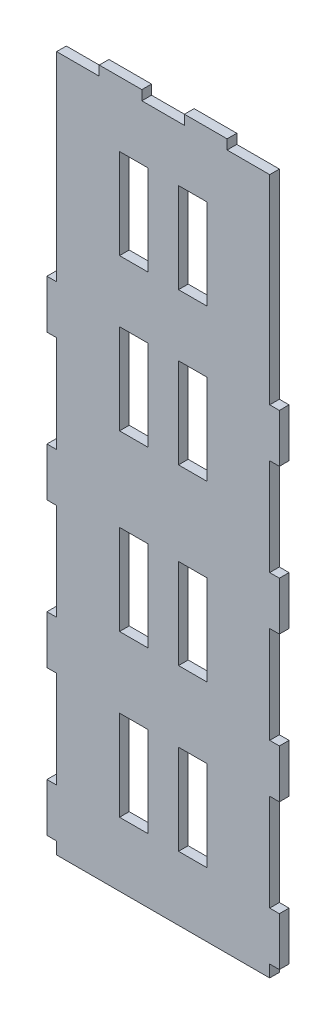
from build123d import *

# Parameters (mm, degrees)
SKETCH1_W           = 11.675882566
SKETCH1_H           = 37.242609939
SKETCH1_H_2         = 37.242609938
BOSS_EXTRUDE1_DEPTH = 4


with BuildPart() as part:
    # Sketch1 → Boss-Extrude1 (new body)
    with BuildSketch(Plane.XY):
        Polygon((6.4, 64.343953413), (-11.2, 64.343953413), (-11.2, 60.343953413), (-28.8, 60.343953413), (-28.8, 64.343953413), (-46.4, 64.343953413), (-46.4, 60.343953413), (-64, 60.343953413), (-64, -21.996281697), (-68, -21.996281697), (-68, -41.996281697), (-64, -41.996281697), (-64, -81.996281697), (-68, -81.996281697), (-68, -101.996281697), (-64, -101.996281697), (-64, -141.996281697), (-68, -141.996281697), (-68, -161.996281697), (-64, -161.996281697), (-64, -201.996281697), (-68, -201.996281697), (-68, -221.996281697), (-64, -221.996281697), (-64, -226.996281697), (24, -226.996281697), (24, -221.996281697), (28, -221.996281697), (28, -201.996281697), (24, -201.996281697), (24, -161.996281697), (28, -161.996281697), (28, -141.996281697), (24, -141.996281697), (24, -101.996281697), (28, -101.996281697), (28, -81.996281697), (24, -81.996281697), (24, -41.996281697), (28, -41.996281697), (28, -21.996281697), (24, -21.996281697), (24, 60.343953413), (6.4, 60.343953413), align=None)
        with Locations((-32.17836291, -181.887864713)):
            Rectangle(SKETCH1_W, SKETCH1_H, mode=Mode.SUBTRACT)
        with Locations((-7.82163709, 18.983890438)):
            Rectangle(SKETCH1_W, SKETCH1_H, mode=Mode.SUBTRACT)
        with Locations((-7.82163709, -43.686747162)):
            Rectangle(SKETCH1_W, SKETCH1_H, mode=Mode.SUBTRACT)
        with Locations((-7.82163709, -115.460501141)):
            Rectangle(SKETCH1_W, SKETCH1_H_2, mode=Mode.SUBTRACT)
        with Locations((-7.82163709, -181.887864713)):
            Rectangle(SKETCH1_W, SKETCH1_H, mode=Mode.SUBTRACT)
        with Locations((-32.17836291, -115.460501141)):
            Rectangle(SKETCH1_W, SKETCH1_H_2, mode=Mode.SUBTRACT)
        with Locations((-32.17836291, -43.686747162)):
            Rectangle(SKETCH1_W, SKETCH1_H, mode=Mode.SUBTRACT)
        with Locations((-32.17836291, 18.983890438)):
            Rectangle(SKETCH1_W, SKETCH1_H, mode=Mode.SUBTRACT)
    extrude(amount=BOSS_EXTRUDE1_DEPTH)


solid = part.part
